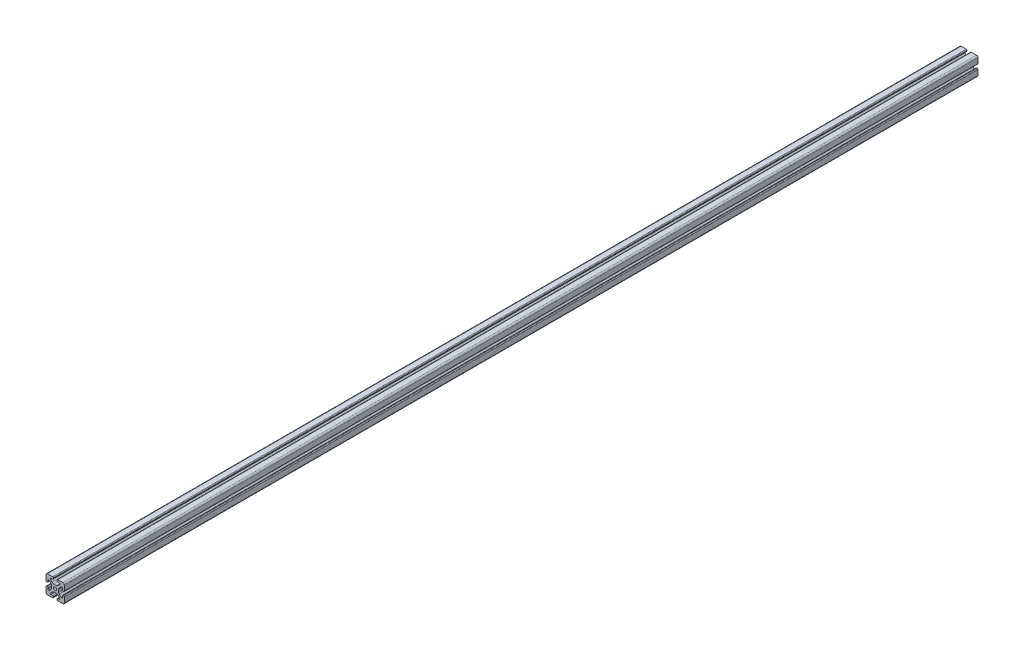
from build123d import *

# Parameters (mm, degrees)
SKETCH1_R           = 3.4
BOSS_EXTRUDE1_DEPTH = 2000


with BuildPart() as part:
    # Sketch1 → Boss-Extrude1 (new body)
    with BuildSketch(Plane.XY):
        with BuildLine():
            Line((-8.715, -15.524615034), (-5.63, -15.524615034))
            ThreePointArc((-5.63, -15.524615034), (-4.519842354, -15.984457388), (-4.06, -17.094615034))
            Line((-4.06, -17.094615034), (-4.06, -18.43))
            ThreePointArc((-4.06, -18.43), (-4.519842354, -19.540157646), (-5.63, -20))
            Line((-5.63, -20), (-16.674615034, -20))
            ThreePointArc((-16.674615034, -20), (-18.951578385, -19.194274381), (-20, -17.018368134))
            Line((-20, -17.018368134), (-20, -5.757918808))
            ThreePointArc((-20, -5.757918808), (-19.564709668, -4.603883664), (-18.43, -4.120449326))
            Line((-18.43, -4.120449326), (-17.248545805, -4.120449326))
            ThreePointArc((-17.248545805, -4.120449326), (-16.114784845, -4.604407881), (-15.67999625, -5.757919334))
            Line((-15.67999625, -5.757919334), (-15.67999625, -8.715399492))
            ThreePointArc((-15.67999625, -8.715399492), (-15.220153896, -9.825557139), (-14.10999625, -10.285399492))
            Line((-14.10999625, -10.285399492), (-13.816903094, -10.285399492))
            ThreePointArc((-13.816903094, -10.285399492), (-13.526063686, -10.227547937), (-13.279501941, -10.062800646))
            Line((-13.279501941, -10.062800646), (-9.076242789, -5.859541495))
            ThreePointArc((-9.076242789, -5.859541495), (-8.046572221, -4.318530588), (-7.685, -2.500784284))
            Line((-7.685, -2.500784284), (-7.685, 2.500784284))
            ThreePointArc((-7.685, 2.500784284), (-8.046572221, 4.318530588), (-9.076242789, 5.859541495))
            Line((-9.076242789, 5.859541495), (-13.040489136, 9.823787841))
            ThreePointArc((-13.040489136, 9.823787841), (-13.354224618, 10.012729352), (-13.71989919, 10.033001362))
            Line((-13.71989919, 10.033001362), (-14.05520779, 10.044710596))
            ThreePointArc((-14.05520779, 10.044710596), (-15.200613642, 9.605030484), (-15.68, 8.475666998))
            Line((-15.68, 8.475666998), (-15.68, 5.572979049))
            ThreePointArc((-15.68, 5.572979049), (-16.139842354, 4.462821403), (-17.25, 4.002979049))
            Line((-17.25, 4.002979049), (-18.43, 4.002979049))
            ThreePointArc((-18.43, 4.002979049), (-19.540157646, 4.462821403), (-20, 5.572979049))
            Line((-20, 5.572979049), (-20, 13.004526564))
            Line((-20, 13.004526564), (-20, 16.83))
            ThreePointArc((-20, 16.83), (-19.071528496, 19.071528496), (-16.83, 20))
            Line((-16.83, 20), (-5.63, 20))
            ThreePointArc((-5.63, 20), (-4.519842354, 19.540157646), (-4.06, 18.43))
            Line((-4.06, 18.43), (-4.06, 17.094615034))
            ThreePointArc((-4.06, 17.094615034), (-4.519842354, 15.984457388), (-5.63, 15.524615034))
            Line((-5.63, 15.524615034), (-8.715, 15.524615034))
            ThreePointArc((-8.715, 15.524615034), (-9.825157646, 15.06477268), (-10.285, 13.954615034))
            Line((-10.285, 13.954615034), (-10.285, 13.492503602))
            ThreePointArc((-10.285, 13.492503602), (-10.227148445, 13.201664194), (-10.062401154, 12.955102448))
            Line((-10.062401154, 12.955102448), (-6.217092793, 9.109794088))
            ThreePointArc((-6.217092793, 9.109794088), (-4.63891877, 8.055291919), (-2.777335583, 7.685))
            Line((-2.777335583, 7.685), (2.777335583, 7.685))
            ThreePointArc((2.777335583, 7.685), (4.63891877, 8.055291919), (6.217092793, 9.109794088))
            Line((6.217092793, 9.109794088), (10.062401154, 12.955102448))
            ThreePointArc((10.062401154, 12.955102448), (10.227148445, 13.201664194), (10.285, 13.492503602))
            Line((10.285, 13.492503602), (10.285, 13.954615034))
            ThreePointArc((10.285, 13.954615034), (9.825157646, 15.06477268), (8.715, 15.524615034))
            Line((8.715, 15.524615034), (5.63, 15.524615034))
            ThreePointArc((5.63, 15.524615034), (4.519842354, 15.984457388), (4.06, 17.094615034))
            Line((4.06, 17.094615034), (4.06, 18.43))
            ThreePointArc((4.06, 18.43), (4.519842354, 19.540157646), (5.63, 20))
            Line((5.63, 20), (12.979635074, 20))
            Line((12.979635074, 20), (16.83, 20))
            ThreePointArc((16.83, 20), (19.071528496, 19.071528496), (20, 16.83))
            Line((20, 16.83), (20, 13.001098436))
            Line((20, 13.001098436), (20, 5.630000526))
            ThreePointArc((20, 5.630000526), (19.540157646, 4.519842879), (18.43, 4.060000526))
            Line((18.43, 4.060000526), (17.24999625, 4.060000526))
            ThreePointArc((17.24999625, 4.060000526), (16.139838603, 4.519842879), (15.67999625, 5.630000526))
            Line((15.67999625, 5.630000526), (15.67999625, 8.715399492))
            ThreePointArc((15.67999625, 8.715399492), (15.220153896, 9.825557139), (14.10999625, 10.285399492))
            Line((14.10999625, 10.285399492), (13.816903094, 10.285399492))
            ThreePointArc((13.816903094, 10.285399492), (13.526063686, 10.227547937), (13.279501941, 10.062800646))
            Line((13.279501941, 10.062800646), (9.076242789, 5.859541495))
            ThreePointArc((9.076242789, 5.859541495), (8.046572221, 4.318530588), (7.685, 2.500784284))
            Line((7.685, 2.500784284), (7.685, -2.500784284))
            ThreePointArc((7.685, -2.500784284), (8.046572221, -4.318530588), (9.076242789, -5.859541495))
            Line((9.076242789, -5.859541495), (13.163657296, -9.946956002))
            ThreePointArc((13.163657296, -9.946956002), (13.35903797, -10.160433474), (13.6200547, -10.285399492))
            Line((13.6200547, -10.285399492), (14.10999625, -10.285399492))
            ThreePointArc((14.10999625, -10.285399492), (15.220153896, -9.825557139), (15.67999625, -8.715399492))
            Line((15.67999625, -8.715399492), (15.67999625, -5.630000526))
            ThreePointArc((15.67999625, -5.630000526), (16.139838603, -4.519842879), (17.24999625, -4.060000526))
            Line((17.24999625, -4.060000526), (18.43, -4.060000526))
            ThreePointArc((18.43, -4.060000526), (19.540157646, -4.519842879), (20, -5.630000526))
            Line((20, -5.630000526), (20, -16.83))
            ThreePointArc((20, -16.83), (19.071528496, -19.071528496), (16.83, -20))
            Line((16.83, -20), (13, -20))
            Line((13, -20), (5.63, -20))
            ThreePointArc((5.63, -20), (4.519842354, -19.540157646), (4.06, -18.43))
            Line((4.06, -18.43), (4.06, -17.094615034))
            ThreePointArc((4.06, -17.094615034), (4.519842354, -15.984457388), (5.63, -15.524615034))
            Line((5.63, -15.524615034), (8.715, -15.524615034))
            ThreePointArc((8.715, -15.524615034), (9.825157646, -15.06477268), (10.285, -13.954615034))
            Line((10.285, -13.954615034), (10.285, -13.492503602))
            ThreePointArc((10.285, -13.492503602), (10.227148445, -13.201664194), (10.062401154, -12.955102448))
            Line((10.062401154, -12.955102448), (6.217092793, -9.109794088))
            ThreePointArc((6.217092793, -9.109794088), (4.63891877, -8.055291919), (2.777335583, -7.685))
            Line((2.777335583, -7.685), (-2.777335583, -7.685))
            ThreePointArc((-2.777335583, -7.685), (-4.63891877, -8.055291919), (-6.217092793, -9.109794088))
            Line((-6.217092793, -9.109794088), (-10.062401154, -12.955102448))
            ThreePointArc((-10.062401154, -12.955102448), (-10.227148445, -13.201664194), (-10.285, -13.492503602))
            Line((-10.285, -13.492503602), (-10.285, -13.954615034))
            ThreePointArc((-10.285, -13.954615034), (-9.825157646, -15.06477268), (-8.715, -15.524615034))
        make_face()
        Circle(SKETCH1_R, mode=Mode.SUBTRACT)
    extrude(amount=BOSS_EXTRUDE1_DEPTH)


solid = part.part
